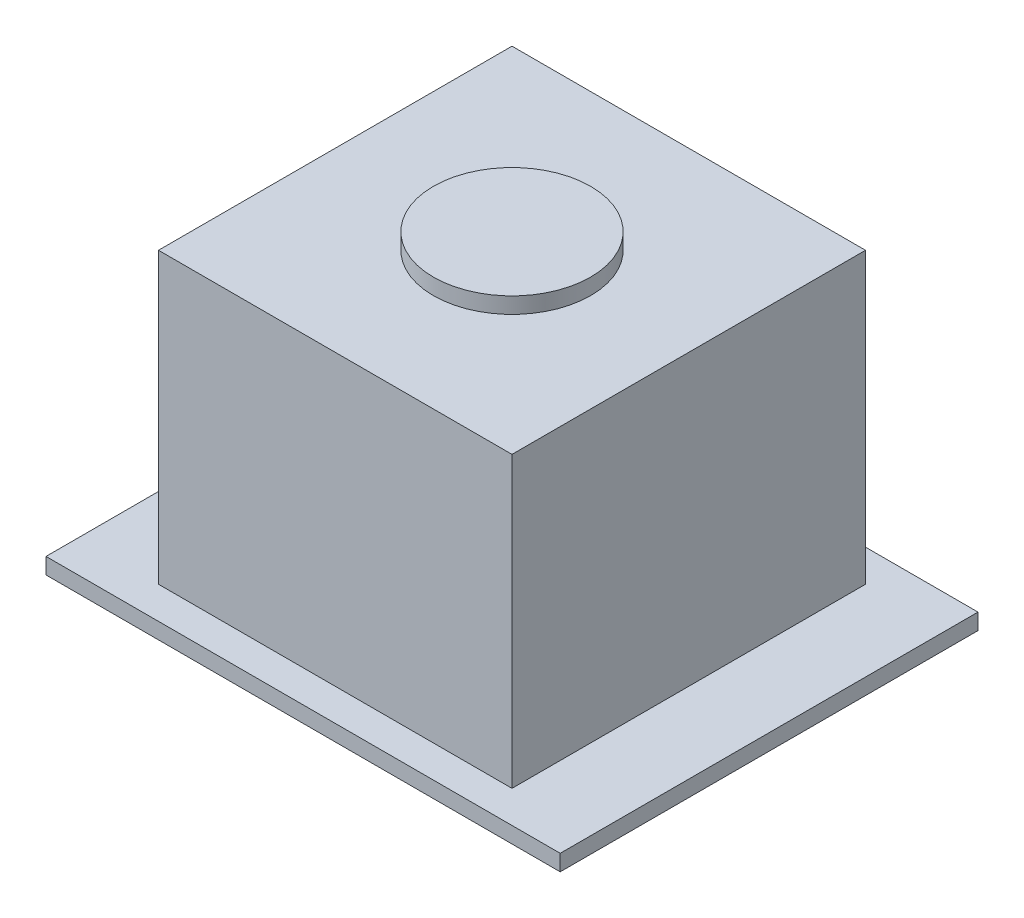
from build123d import *

# Parameters (mm, degrees)
SKETCH1_W           = 11
SKETCH1_H           = 11
BOSS_EXTRUDE1_DEPTH = 9
SKETCH2_W           = 16
SKETCH2_H           = 13
BOSS_EXTRUDE2_DEPTH = 0.5
SKETCH3_R           = 2.446587027
BOSS_EXTRUDE3_DEPTH = 0.5


with BuildPart() as part:
    # Sketch1 → Boss-Extrude1 (new body)
    with BuildSketch(Plane(origin=(0, 0, 0), x_dir=(1, 0, 0), z_dir=(0, 1, 0))):
        with Locations((138.476530612, -102.126020408)):
            Rectangle(SKETCH1_W, SKETCH1_H)
    extrude(amount=BOSS_EXTRUDE1_DEPTH)

    # Sketch2 → Boss-Extrude2 (add)
    with BuildSketch(Plane.XZ):
        with Locations((138.476530612, 102.126020408)):
            Rectangle(SKETCH2_W, SKETCH2_H)
    extrude(amount=BOSS_EXTRUDE2_DEPTH)

    # Sketch3 → Boss-Extrude3 (add)
    with BuildSketch(Plane(origin=(0, 9, 0), x_dir=(1, 0, 0), z_dir=(0, 1, 0))):
        with Locations((138.476530612, -102.126020408)):
            Circle(SKETCH3_R)
    extrude(amount=BOSS_EXTRUDE3_DEPTH)


solid = part.part
